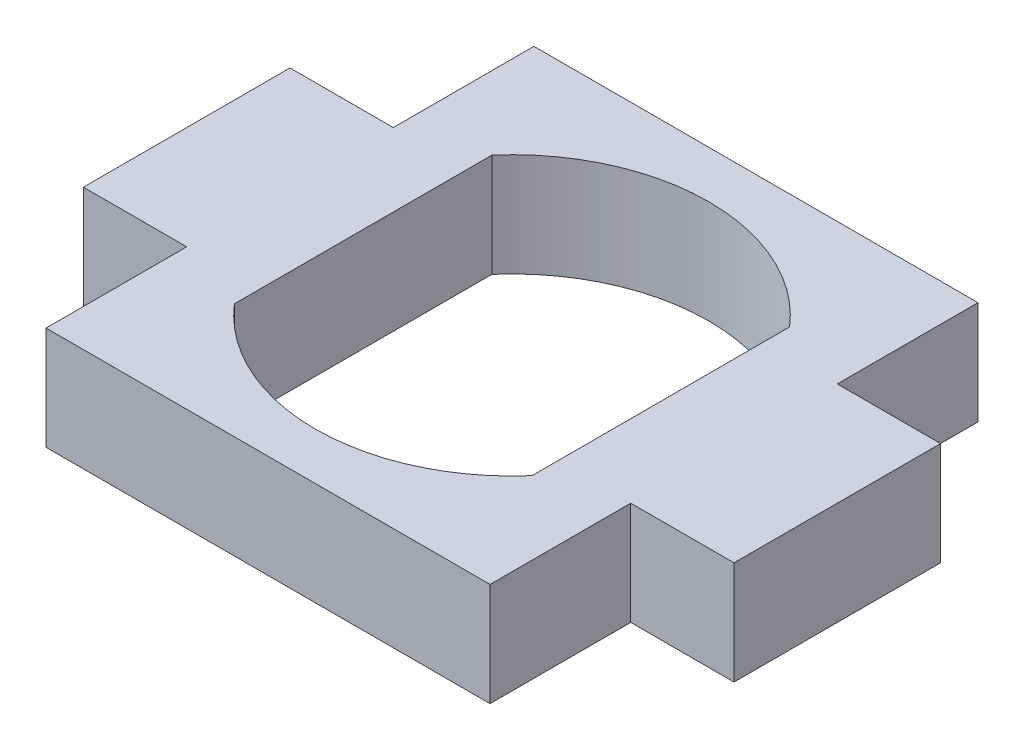
from build123d import *

# Parameters (mm, degrees)
SKETCH1_W           = 27.3
SKETCH1_H           = 30
BOSS_EXTRUDE1_DEPTH = 6.35
SKETCH2_W           = 12.7
SKETCH2_H           = 6.35
BOSS_EXTRUDE2_DEPTH = 6.35
CUT_EXTRUDE1_DEPTH  = 7.35


with BuildPart() as part:
    # Sketch1 → Boss-Extrude1 (new body)
    with BuildSketch(Plane(origin=(0, 0, 0), x_dir=(1, 0, 0), z_dir=(0, 1, 0))):
        Rectangle(SKETCH1_W, SKETCH1_H)
    extrude(amount=BOSS_EXTRUDE1_DEPTH)

    # Sketch2 → Boss-Extrude2 (add)
    with BuildSketch(Plane(origin=(13.65, 0, 0), x_dir=(0, 0, -1), z_dir=(1, 0, 0))):
        with Locations((0, 3.175)):
            Rectangle(SKETCH2_W, SKETCH2_H)
    boss_extrude2 = extrude(amount=BOSS_EXTRUDE2_DEPTH)

    # Mirror1: Boss-Extrude2 across plane
    add(boss_extrude2.mirror(Plane(origin=(0, 0, 0), x_dir=(0, 0, 1), z_dir=(1, 0, 0))))

    # Sketch3 → Cut-Extrude1 (cut, through all)
    with BuildSketch(Plane(origin=(0, 6.35, 0), x_dir=(1, 0, 0), z_dir=(0, 1, 0))):
        with BuildLine():
            Line((-9.15, -7.917543811), (-9.15, 7.917543811))
            ThreePointArc((-9.15, 7.917543811), (0, 12.1), (9.15, 7.917543811))
            Line((9.15, 7.917543811), (9.15, -7.917543811))
            ThreePointArc((9.15, -7.917543811), (0, -12.1), (-9.15, -7.917543811))
        make_face()
    extrude(amount=-CUT_EXTRUDE1_DEPTH, mode=Mode.SUBTRACT)


solid = part.part
